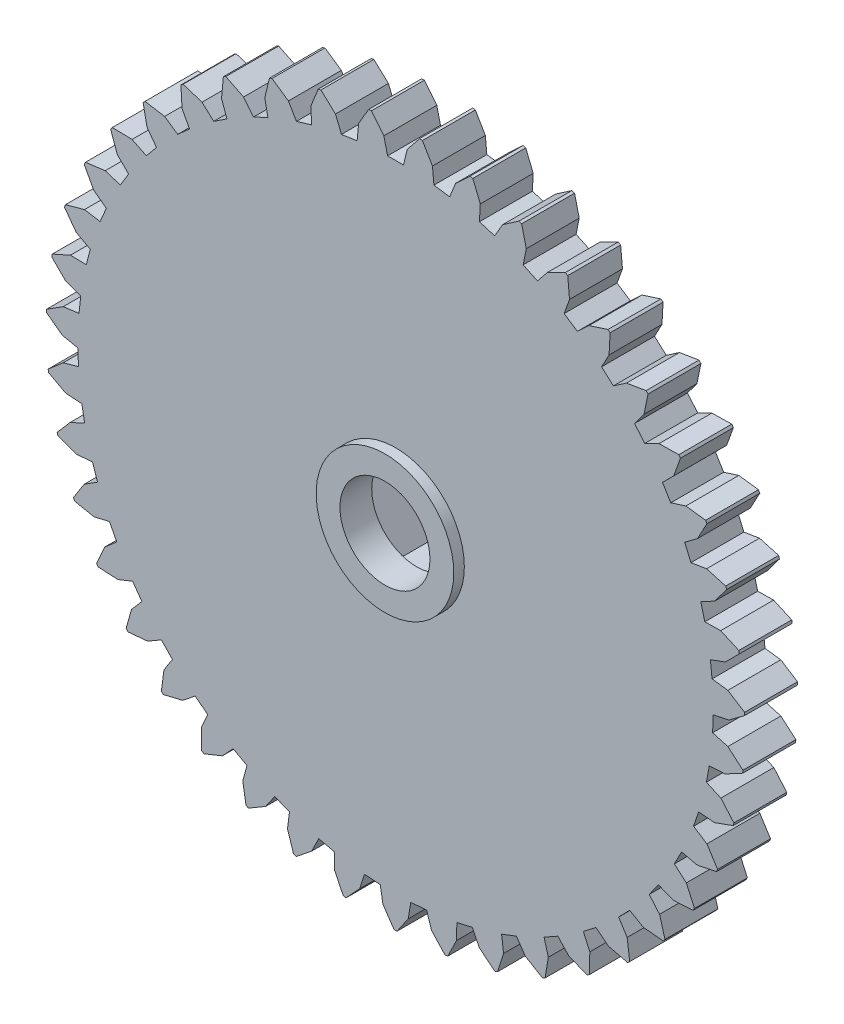
from build123d import *

# Parameters (mm, degrees)
ESQUISSE1_R                  = 33
BOSS_EXTRU_1_DEPTH           = 5
ENL_V_MAT_EXTRU_1_DEPTH      = 6
R_P_TITION_CIRCULAIRE1_COUNT = 43
ESQUISSE3_R                  = 10.5
BOSS_EXTRU_2_DEPTH           = 3
ENL_V_MAT_EXTRU_2_DEPTH      = 6
ENL_V_MAT_EXTRU_3_REACH      = 49.041
ESQUISSE5_R                  = 4.25
ESQUISSE7_R                  = 6.5
ESQUISSE7_R_2                = 4.25
BOSS_EXTRU_3_DEPTH           = 1


with BuildPart() as part:
    # Esquisse1 → Boss.-Extru.1 (new body)
    with BuildSketch(Plane.XY):
        Circle(ESQUISSE1_R)
    extrude(amount=BOSS_EXTRU_1_DEPTH)

    # Esquisse2 → Enlèv. mat.-Extru.1 (cut)
    with BuildSketch(Plane(origin=(0, 0, 0), x_dir=(-1, 0, 0), z_dir=(0, 0, -1))):
        with BuildLine():
            Line((-2.27740903, 32.921321482), (-1.105, 31.457386359))
            Line((-1.105, 31.457386359), (-0.75, 30))
            Line((-0.75, 30), (0.75, 30))
            Line((0.75, 30), (1.105, 31.457386359))
            Line((1.105, 31.457386359), (2.27740903, 32.921321482))
            ThreePointArc((2.27740903, 32.921321482), (0, 33), (-2.27740903, 32.921321482))
        make_face()
    enl_v_mat_extru_1 = extrude(amount=-ENL_V_MAT_EXTRU_1_DEPTH, mode=Mode.SUBTRACT)

    # Répétition circulaire1: Enlèv. mat.-Extru.1 ×43 about axis
    r_p_tition_circulaire1_axis = Axis((0, 0, 0), (0, 0, 1))
    for i in range(1, R_P_TITION_CIRCULAIRE1_COUNT):
        add(enl_v_mat_extru_1.rotate(r_p_tition_circulaire1_axis, i * 360 / R_P_TITION_CIRCULAIRE1_COUNT), mode=Mode.SUBTRACT)

    # Esquisse3 → Boss.-Extru.2 (add)
    with BuildSketch(Plane(origin=(0, 0, 0), x_dir=(-1, 0, 0), z_dir=(0, 0, -1))):
        with Locations(Location((0, 0, 0), (0, 0, 180))):
            Circle(ESQUISSE3_R)
    extrude(amount=BOSS_EXTRU_2_DEPTH)

    # Esquisse4 → Enlèv. mat.-Extru.2 (cut)
    with BuildSketch(Plane(origin=(0, 0, -3), x_dir=(-1, 0, 0), z_dir=(0, 0, -1))):
        Polygon((3.75277675, -6.5), (7.505553499, 0), (3.75277675, 6.5), (-3.75277675, 6.5), (-7.505553499, 0), (-3.75277675, -6.5), align=None)
    extrude(amount=-ENL_V_MAT_EXTRU_2_DEPTH, mode=Mode.SUBTRACT)

    # Esquisse5 → Enlèv. mat.-Extru.3 (cut, up to next)
    with BuildSketch(Plane(origin=(0, 0, 3), x_dir=(-1, 0, 0), z_dir=(0, 0, -1)), mode=Mode.PRIVATE) as enl_v_mat_extru_3_sk1:
        Circle(ESQUISSE5_R)
    enl_v_mat_extru_3_tool1 = extrude(enl_v_mat_extru_3_sk1.sketch, amount=-ENL_V_MAT_EXTRU_3_REACH, mode=Mode.PRIVATE) & part.part
    add(enl_v_mat_extru_3_tool1.solids().sort_by_distance((0, 0, 3))[0], mode=Mode.SUBTRACT)

    # Esquisse7 → Boss.-Extru.3 (add)
    with BuildSketch(Plane.XY.offset(5)):
        Circle(ESQUISSE7_R)
        with Locations(Location((0, 0, 0), (0, 0, 180))):
            Circle(ESQUISSE7_R_2, mode=Mode.SUBTRACT)
    extrude(amount=BOSS_EXTRU_3_DEPTH)


solid = part.part
